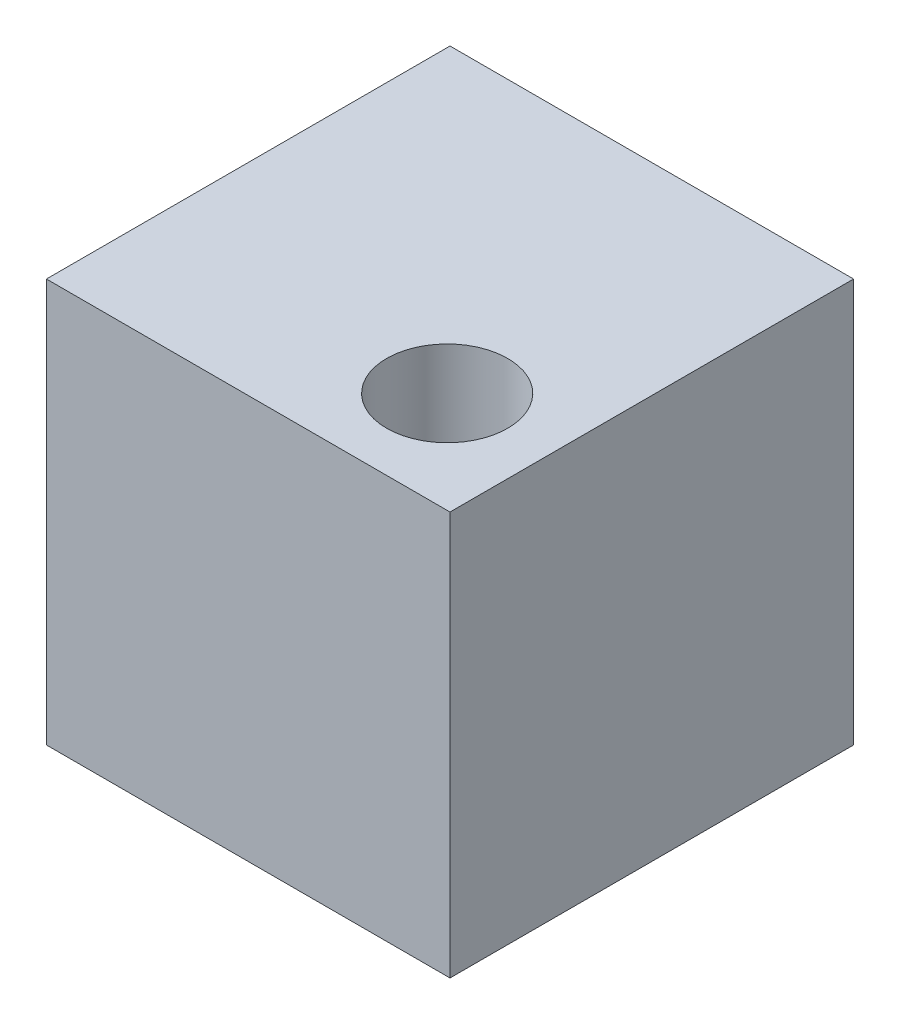
from build123d import *

# Parameters (mm, degrees)
SKETCH1_W           = 10
SKETCH1_H           = 10
BOSS_EXTRUDE1_DEPTH = 10
SKETCH2_R           = 1.5
CUT_EXTRUDE1_DEPTH  = 5


with BuildPart() as part:
    # Sketch1 → Boss-Extrude1 (new body)
    with BuildSketch(Plane(origin=(0, 0, 0), x_dir=(1, 0, 0), z_dir=(0, 1, 0))):
        with Locations((1.337358276, -2.806166958)):
            Rectangle(SKETCH1_W, SKETCH1_H)
    extrude(amount=BOSS_EXTRUDE1_DEPTH)

    # Sketch2 → Cut-Extrude1 (cut)
    with BuildSketch(Plane(origin=(0, 10, 0), x_dir=(1, 0, 0), z_dir=(0, 1, 0))):
        with Locations((3.756342699, -5.295200926)):
            Circle(SKETCH2_R)
    extrude(amount=-CUT_EXTRUDE1_DEPTH, mode=Mode.SUBTRACT)


solid = part.part
